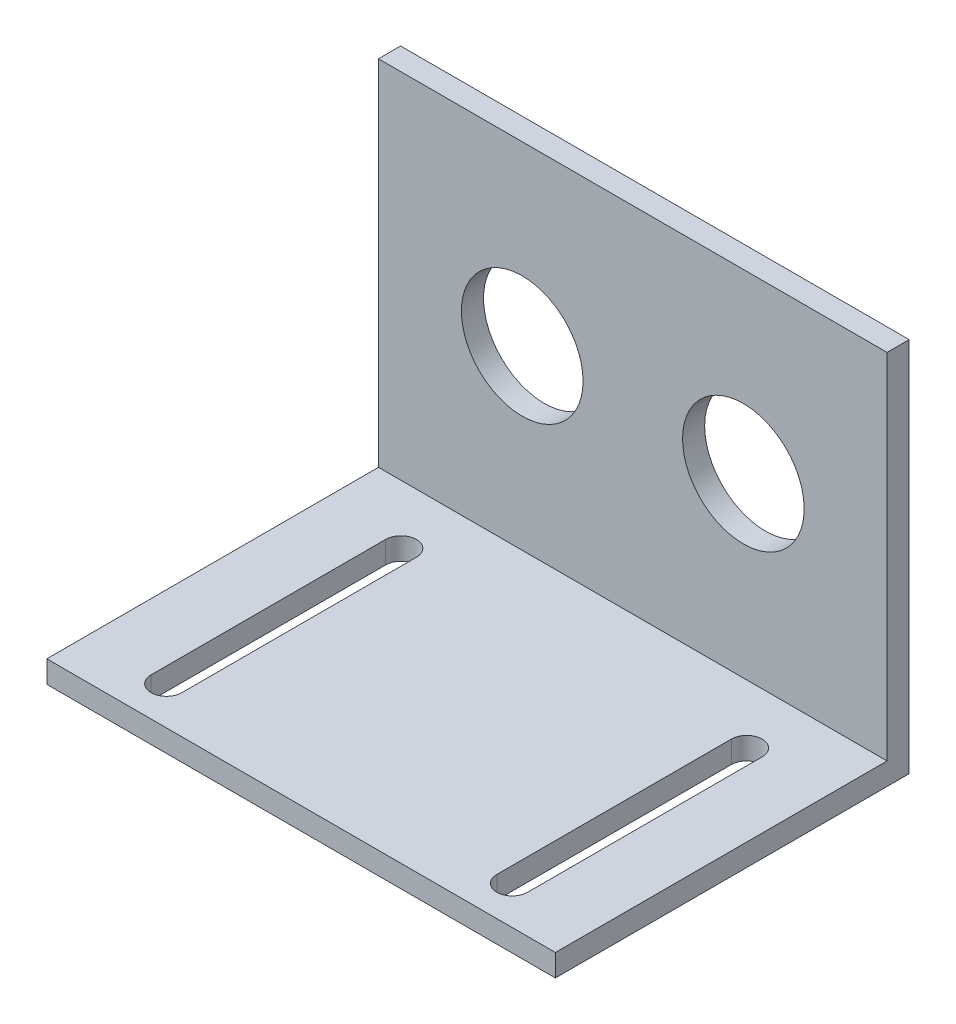
from build123d import *

# Parameters (mm, degrees)
SKETCH_1_W          = 46
SKETCH_1_H          = 34
EXTRUDE_1_DEPTH     = 2
SKETCH_2_W          = 46
SKETCH_2_H          = 2
EXTRUDE_2_DEPTH     = 30
SKETCH_3_R          = 5.5
CUT_EXTRUDE_1_DEPTH = 2
CUT_EXTRUDE_2_DEPTH = 2


with BuildPart() as part:
    # 草图1 → 凸台-拉伸1 (new body)
    with BuildSketch(Plane.XY):
        with Locations((-7.206275861, 17)):
            Rectangle(SKETCH_1_W, SKETCH_1_H)
    extrude(amount=EXTRUDE_1_DEPTH)

    # 草图2 → 凸台-拉伸2 (add)
    with BuildSketch(Plane.XY.offset(2)):
        with Locations((-7.206275861, 1)):
            Rectangle(SKETCH_2_W, SKETCH_2_H)
    extrude(amount=EXTRUDE_2_DEPTH)

    # 草图3 → 切除-拉伸1 (cut)
    with BuildSketch(Plane.XY.offset(2)):
        with Locations((-17.206275861, 18)):
            Circle(SKETCH_3_R)
        with Locations((2.793724139, 18)):
            Circle(SKETCH_3_R)
    extrude(amount=-CUT_EXTRUDE_1_DEPTH, mode=Mode.SUBTRACT)

    # 草图4 → 切除-拉伸2 (cut)
    with BuildSketch(Plane(origin=(0, 2, 0), x_dir=(1, 0, 0), z_dir=(0, 1, 0))):
        with BuildLine():
            Line((-24.235699599, -7.328343443), (-24.235699599, -28.539953108))
            ThreePointArc((-24.235699599, -28.539953108), (-22.841637624, -29.934015083), (-21.447575649, -28.539953108))
            Line((-21.447575649, -28.539953108), (-21.447575649, -7.328343443))
            ThreePointArc((-21.447575649, -7.328343443), (-22.841637624, -5.934281468), (-24.235699599, -7.328343443))
        make_face()
        with BuildLine():
            Line((7.035023927, -7.328343443), (7.035023927, -28.539953108))
            ThreePointArc((7.035023927, -28.539953108), (8.429085903, -29.934015083), (9.823147878, -28.539953108))
            Line((9.823147878, -28.539953108), (9.823147878, -7.328343443))
            ThreePointArc((9.823147878, -7.328343443), (8.429085903, -5.934281468), (7.035023927, -7.328343443))
        make_face()
    extrude(amount=-CUT_EXTRUDE_2_DEPTH, mode=Mode.SUBTRACT)


solid = part.part
